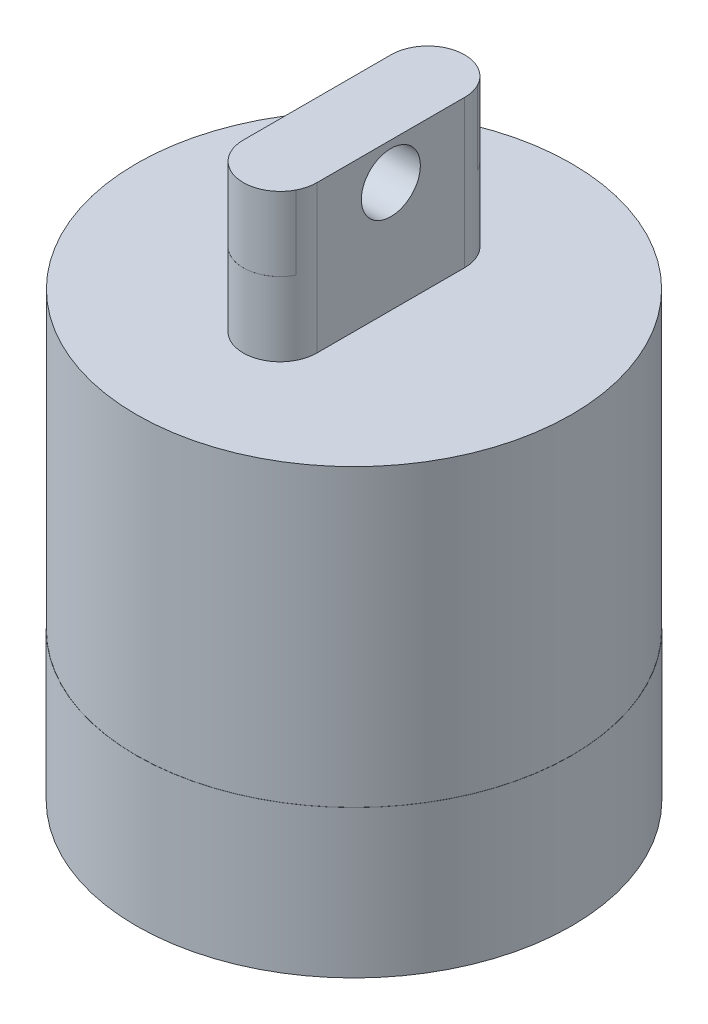
from build123d import *

# Parameters (mm, degrees)
SKETCH1_R               = 38.1
BOSS_EXTRUDE1_DEPTH     = 63.5
BOSS_EXTRUDE2_DEPTH     = 76.2
SKETCH3_R               = 5.08
CUT_EXTRUDE1_DEPTH      = 76.2
CUT_EXTRUDE1_DEPTH_BACK = 76.2
SKETCH4_R               = 50.8
SKETCH4_R_2             = 37.439644023
CUT_EXTRUDE4_DEPTH      = 76.2
CUT_EXTRUDE4_DEPTH_BACK = 76.2
SKETCH5_R               = 38.1
CUT_EXTRUDE8_DEPTH      = 25.4
SKETCH6_R               = 37.465
BOSS_EXTRUDE4_DEPTH     = 25.4


with BuildPart() as part:
    # Sketch1 → Boss-Extrude1 (new body)
    with BuildSketch(Plane(origin=(0, 0, 0), x_dir=(1, 0, 0), z_dir=(0, 1, 0))):
        Circle(SKETCH1_R)
    extrude(amount=BOSS_EXTRUDE1_DEPTH)

    # Sketch2 → Boss-Extrude2 (add)
    with BuildSketch(Plane(origin=(0, 0, 0), x_dir=(1, 0, 0), z_dir=(0, 1, 0))):
        with BuildLine():
            Line((-6.35, -12.7), (-6.35, 12.7))
            ThreePointArc((-6.35, 12.7), (0, 19.05), (6.35, 12.7))
            Line((6.35, 12.7), (6.35, -12.7))
            ThreePointArc((6.35, -12.7), (0, -19.05), (-6.35, -12.7))
        make_face()
    extrude(amount=BOSS_EXTRUDE2_DEPTH)

    # Sketch3 → Cut-Extrude1 (cut, two sides)
    with BuildSketch(Plane(origin=(0, 0, 0), x_dir=(0, 0, -1), z_dir=(1, 0, 0))) as cut_extrude1_sk:
        with Locations((0, 69.85)):
            Circle(SKETCH3_R)
    extrude(amount=CUT_EXTRUDE1_DEPTH, mode=Mode.SUBTRACT)
    extrude(cut_extrude1_sk.sketch, amount=-CUT_EXTRUDE1_DEPTH_BACK, mode=Mode.SUBTRACT)

    # Sketch4 → Cut-Extrude4 (cut, two sides)
    with BuildSketch(Plane(origin=(0, 0, 0), x_dir=(1, 0, 0), z_dir=(0, 1, 0))) as cut_extrude4_sk:
        Circle(SKETCH4_R)
        Circle(SKETCH4_R_2, mode=Mode.SUBTRACT)
    extrude(amount=CUT_EXTRUDE4_DEPTH, mode=Mode.SUBTRACT)
    extrude(cut_extrude4_sk.sketch, amount=-CUT_EXTRUDE4_DEPTH_BACK, mode=Mode.SUBTRACT)

    # Sketch5 → Cut-Extrude8 (cut)
    with BuildSketch(Plane(origin=(0, 76.2, 0), x_dir=(1, 0, 0), z_dir=(0, 1, 0))):
        Circle(SKETCH5_R)
        with BuildLine():
            Line((-6.341677417, -12.718199215), (-6.341677417, 12.718199215))
            ThreePointArc((-6.341677417, 12.718199215), (0, 19.059876632), (6.341677417, 12.718199215))
            Line((6.341677417, 12.718199215), (6.341677417, -12.718199215))
            ThreePointArc((6.341677417, -12.718199215), (0, -19.059876632), (-6.341677417, -12.718199215))
        make_face(mode=Mode.SUBTRACT)
    extrude(amount=-CUT_EXTRUDE8_DEPTH, mode=Mode.SUBTRACT)

    # Sketch6 → Boss-Extrude4 (add)
    with BuildSketch(Plane(origin=(0, 0, 0), x_dir=(-1, 0, 0), z_dir=(0, -1, 0))):
        Circle(SKETCH6_R)
    extrude(amount=BOSS_EXTRUDE4_DEPTH)


solid = part.part
